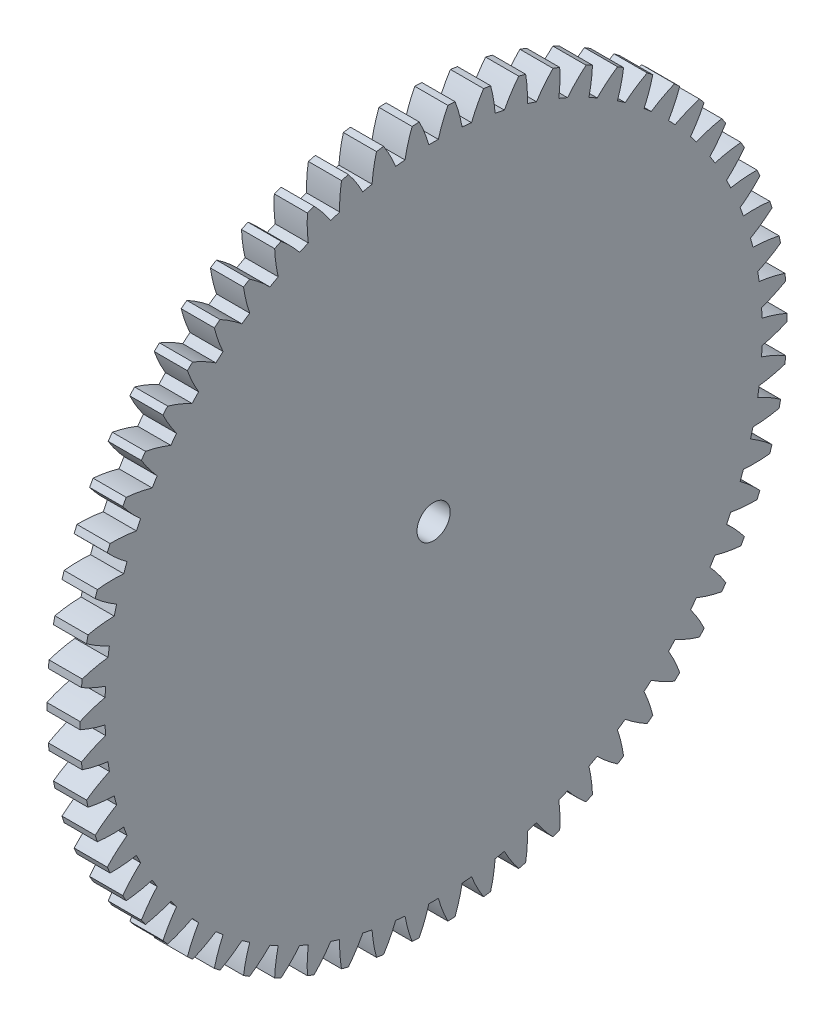
from build123d import *

# Parameters (mm, degrees)
BASPROSKE_W     = 3
BASPROSKE_H     = 32
TOOTHCUT_DEPTH  = 46.354161882
TEETHCUTS_COUNT = 62
TEETHCUTS_ANGLE = 354.193548387
BORSKE_R        = 1.5
BORE_DEPTH      = 50.0000508


with BuildPart() as part:
    # BasProSke → Base-Revolve (revolve)
    with BuildSketch(Plane(origin=(0, 0, 0), x_dir=(1, 0, 0), z_dir=(0, 1, 0)), mode=Mode.PRIVATE) as base_revolve_sk:
        with Locations((1.5, 16)):
            Rectangle(BASPROSKE_W, BASPROSKE_H)
    revolve(base_revolve_sk.sketch.rotate(Axis((-10, 0, 0), (1, 0, 0)), 180), axis=Axis((-10, 0, 0), (1, 0, 0)))

    # TooCutSke → ToothCut (cut, through all)
    with BuildSketch(Plane(origin=(0, 0, 0), x_dir=(0, 0, -1), z_dir=(1, 0, 0))):
        with BuildLine():
            ThreePointArc((0.428926933, 29.745907663), (0, 29.749), (-0.428926933, 29.745907663))
            ThreePointArc((-0.428926933, 29.745907663), (-0.814399528, 30.893786924), (-1.30999226, 31.998596304))
            ThreePointArc((-1.30999226, 31.998596304), (0, 32.0254), (1.30999226, 31.998596304))
            ThreePointArc((1.30999226, 31.998596304), (0.814399528, 30.893786924), (0.428926933, 29.745907663))
        make_face()
    toothcut = extrude(amount=TOOTHCUT_DEPTH, mode=Mode.SUBTRACT)

    # TeethCuts: ToothCut ×62 about axis
    teethcuts_axis = Axis((-10, 0, 0), (1, 0, 0))
    for i in range(1, TEETHCUTS_COUNT):
        add(toothcut.rotate(teethcuts_axis, i * TEETHCUTS_ANGLE / (TEETHCUTS_COUNT - 1)), mode=Mode.SUBTRACT)

    # BorSke → Bore (cut, symmetric)
    with BuildSketch(Plane(origin=(0, 0, 0), x_dir=(0, 0, -1), z_dir=(1, 0, 0))):
        with Locations(Location((0, 0, 0), (0, 0, 180))):
            Circle(BORSKE_R)
    extrude(amount=BORE_DEPTH, both=True, mode=Mode.SUBTRACT)


solid = part.part
